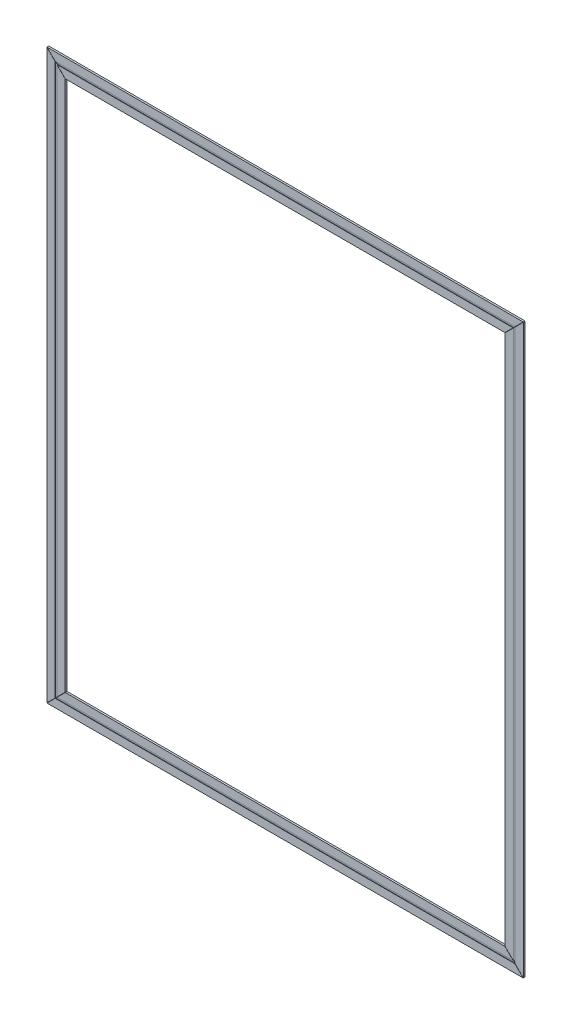
from build123d import *

# Parameters (mm, degrees)
CROQUIS1_W                = 498
CROQUIS1_H                = 598
CROQUIS1_W_2              = 480
CROQUIS1_H_2              = 580
SALIENTE_EXTRUIR1_DEPTH   = 2
CROQUIS1_W_3              = 520
CROQUIS1_H_3              = 620
CROQUIS1_W_4              = 502
CROQUIS1_H_4              = 602
SALIENTE_EXTRUIR1_2_DEPTH = 2
CROQUIS1_3_W              = 502
CROQUIS1_3_H              = 602
CROQUIS1_3_W_2            = 498
CROQUIS1_3_H_2            = 598
SALIENTE_EXTRUIR2_DEPTH   = 1.5
CORTAR_EXTRUIR1_DEPTH     = 21


with BuildPart() as part:
    # Croquis1 → Saliente-Extruir1 (new body)
    with BuildSketch(Plane.XY):
        Rectangle(CROQUIS1_W, CROQUIS1_H)
        Rectangle(CROQUIS1_W_2, CROQUIS1_H_2, mode=Mode.SUBTRACT)
    extrude(amount=SALIENTE_EXTRUIR1_DEPTH)



with BuildPart() as body_2:
    # Croquis1 → Saliente-Extruir1 2 (new body)
    with BuildSketch(Plane.XY):
        Rectangle(CROQUIS1_W_3, CROQUIS1_H_3)
        Rectangle(CROQUIS1_W_4, CROQUIS1_H_4, mode=Mode.SUBTRACT)
    extrude(amount=SALIENTE_EXTRUIR1_2_DEPTH)


with BuildPart() as part_1:
    add(part.part)

    add(body_2.part)  # Saliente-Extruir2 merges body 2
    # Croquis1_3 → Saliente-Extruir2 (add)
    with BuildSketch(Plane.XY):
        Rectangle(CROQUIS1_3_W, CROQUIS1_3_H)
        Rectangle(CROQUIS1_3_W_2, CROQUIS1_3_H_2, mode=Mode.SUBTRACT)
    extrude(amount=SALIENTE_EXTRUIR2_DEPTH)

    # Croquis2 → Cortar-Extruir1 (cut)
    with BuildSketch(Plane.XY.offset(2)):
        Polygon((-240, 289.8), (-260, 309.8), (-260, 310), (-259.8, 310), (-239.8, 290), (-240, 290), align=None)
        Polygon((240, 290), (240, 289.8), (260, 309.8), (260, 310), (259.8, 310), (239.8, 290), align=None)
        Polygon((240, -289.8), (260, -309.8), (260, -310), (259.8, -310), (239.8, -290), (240, -290), align=None)
        Polygon((-240, -290), (-240, -289.8), (-260, -309.8), (-260, -310), (-259.8, -310), (-239.8, -290), align=None)
    extrude(amount=-CORTAR_EXTRUIR1_DEPTH, mode=Mode.SUBTRACT)


with BuildPart() as cortar_extruir1_piece_1:
    # of the separate pieces the step leaves, piece 1, a body of its own (cortar_extruir1_pieces)
    add(part_1.part.solids().sort_by_distance((-249, -298.8, 1.5))[0])


with BuildPart() as cortar_extruir1_piece_2:
    # of the separate pieces the step leaves, piece 2, a body of its own (cortar_extruir1_pieces)
    add(part_1.part.solids().sort_by_distance((249, -298.8, 2))[0])


with BuildPart() as cortar_extruir1_piece_3:
    # of the separate pieces the step leaves, piece 3, a body of its own (cortar_extruir1_pieces)
    add(part_1.part.solids().sort_by_distance((248.8, -299, 2))[0])


with BuildPart() as cortar_extruir1_piece_4:
    # of the separate pieces the step leaves, piece 4, a body of its own (cortar_extruir1_pieces)
    add(part_1.part.solids().sort_by_distance((248.8, 299, 2))[0])


solid = Compound([cortar_extruir1_piece_1.part, cortar_extruir1_piece_2.part, cortar_extruir1_piece_3.part, cortar_extruir1_piece_4.part])
